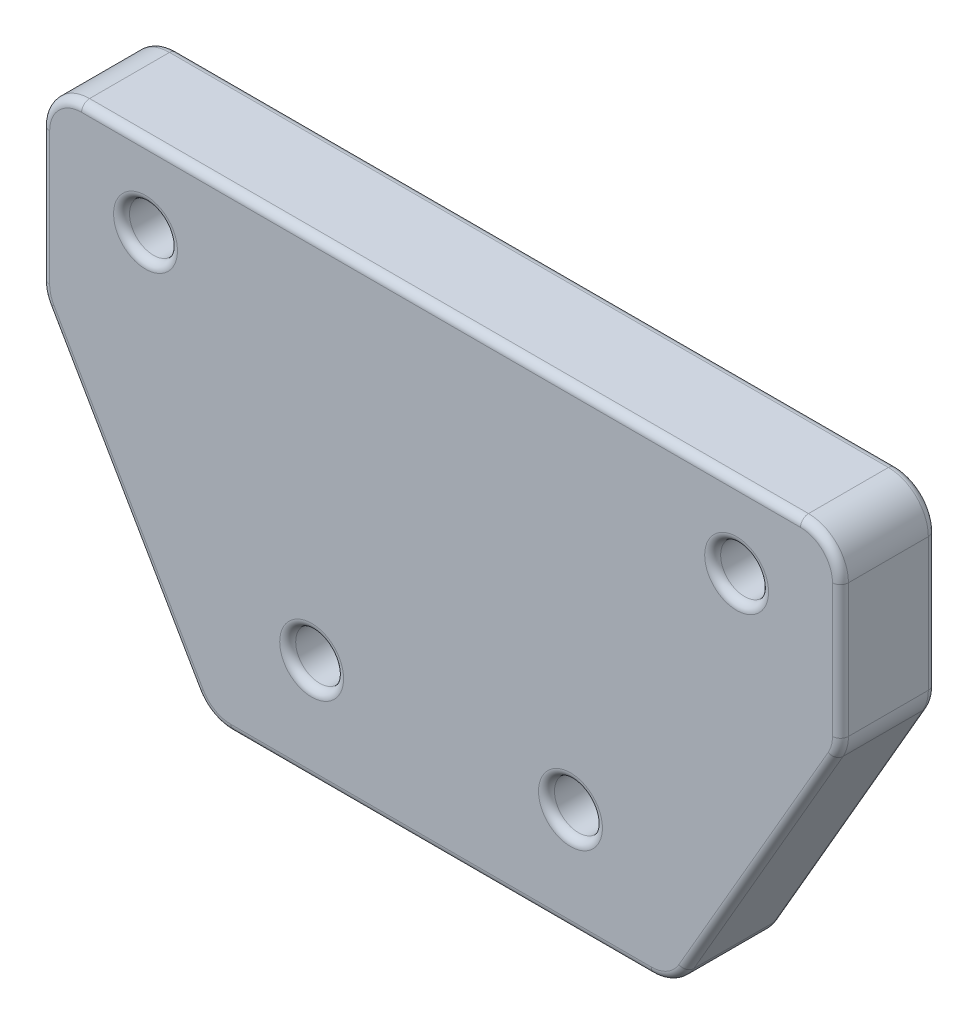
from build123d import *

# Parameters (mm, degrees)
SKETCH1_R           = 1.5
BOSS_EXTRUDE1_DEPTH = 6
FILLET1_R           = 2.5
FILLET2_R           = 0.5


with BuildPart() as part:
    # Sketch1 → Boss-Extrude1 (new body)
    with BuildSketch(Plane.XY):
        Polygon((-14.6, -44.3), (14.6, -44.3), (25, -26.3), (25, -14.8), (-25, -14.8), (-25, -26.3), align=None)
        with Locations((-18.5, -19.8)):
            Circle(SKETCH1_R, mode=Mode.SUBTRACT)
        with Locations((18.5, -19.8)):
            Circle(SKETCH1_R, mode=Mode.SUBTRACT)
        with Locations((8.1, -37.8)):
            Circle(SKETCH1_R, mode=Mode.SUBTRACT)
        with Locations((-8.1, -37.8)):
            Circle(SKETCH1_R, mode=Mode.SUBTRACT)
    extrude(amount=BOSS_EXTRUDE1_DEPTH)

    # Fillet1
    fillet1_edges = [part.edges().sort_by_distance(p)[0] for p in [
        (-25, -26.3, 3),
        (-25, -14.8, 3),
        (25, -14.8, 3),
        (25, -26.3, 3),
        (14.6, -44.3, 3),
        (-14.6, -44.3, 3),
    ]]
    fillet(fillet1_edges, radius=FILLET1_R)

    # Fillet2
    fillet2_edges = [part.edges().sort_by_distance(p)[0] for p in [
        (-20, -19.8, 0),
        (-20, -19.8, 6),
        (17, -19.8, 0),
        (17, -19.8, 6),
        (6.6, -37.8, 0),
        (6.6, -37.8, 6),
        (-9.6, -37.8, 0),
        (-9.6, -37.8, 6),
        (0, -14.8, 0),
        (0, -14.8, 6),
        (-19.993241965, -34.965542752, 0),
        (-25, -21.464848758, 0),
        (25, -21.464848758, 0),
        (19.993241965, -34.965542752, 0),
        (0, -44.3, 0),
        (-14.406811519, -43.965263839, 0),
        (-24.914710822, -26.277132181, 0),
        (-24.267766953, -15.532233047, 0),
        (14.406811519, -43.965263839, 0),
        (24.914710822, -26.277132181, 0),
        (24.267766953, -15.532233047, 0),
        (25, -21.464848758, 6),
        (-19.993241965, -34.965542752, 6),
        (0, -44.3, 6),
        (19.993241965, -34.965542752, 6),
        (-25, -21.464848758, 6),
        (-14.406811519, -43.965263839, 6),
        (-24.914710822, -26.277132181, 6),
        (-24.267766953, -15.532233047, 6),
        (14.406811519, -43.965263839, 6),
        (24.914710822, -26.277132181, 6),
        (24.267766953, -15.532233047, 6),
    ]]
    fillet(fillet2_edges, radius=FILLET2_R)


solid = part.part
